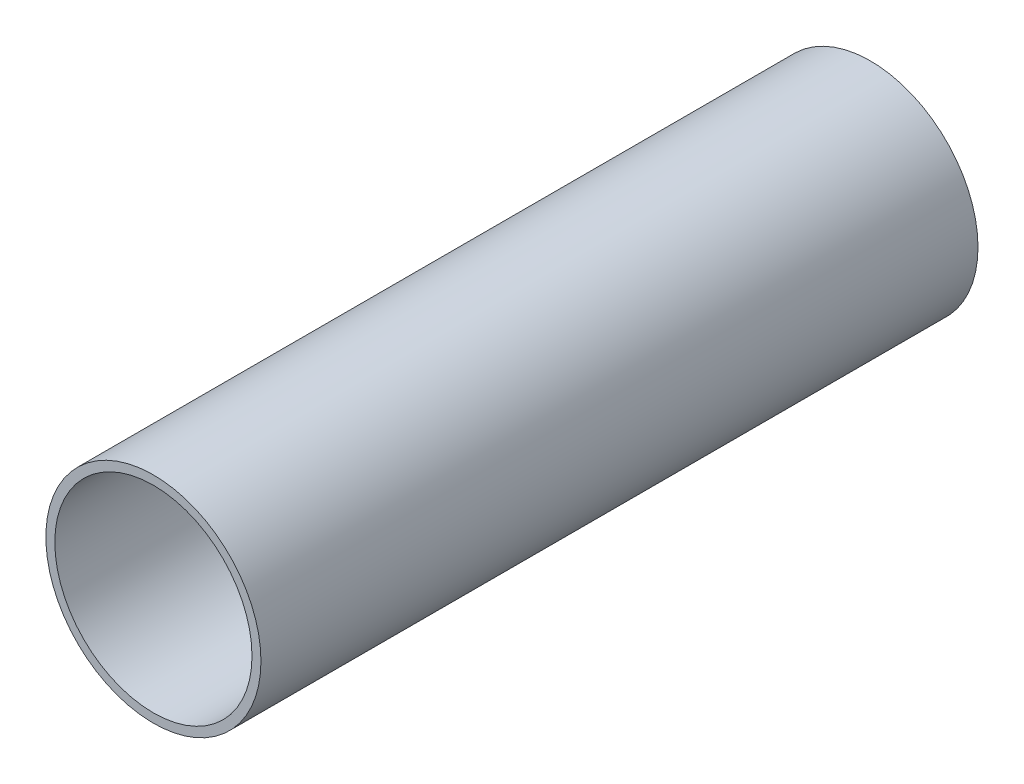
from build123d import *

# Parameters (mm, degrees)
SKETCH2_R           = 38.1
SKETCH2_R_2         = 34.925
BOSS_EXTRUDE1_DEPTH = 254


with BuildPart() as part:
    # Sketch2 → Boss-Extrude1 (new body)
    with BuildSketch(Plane.XY):
        Circle(SKETCH2_R)
        Circle(SKETCH2_R_2, mode=Mode.SUBTRACT)
    extrude(amount=-BOSS_EXTRUDE1_DEPTH)


solid = part.part
